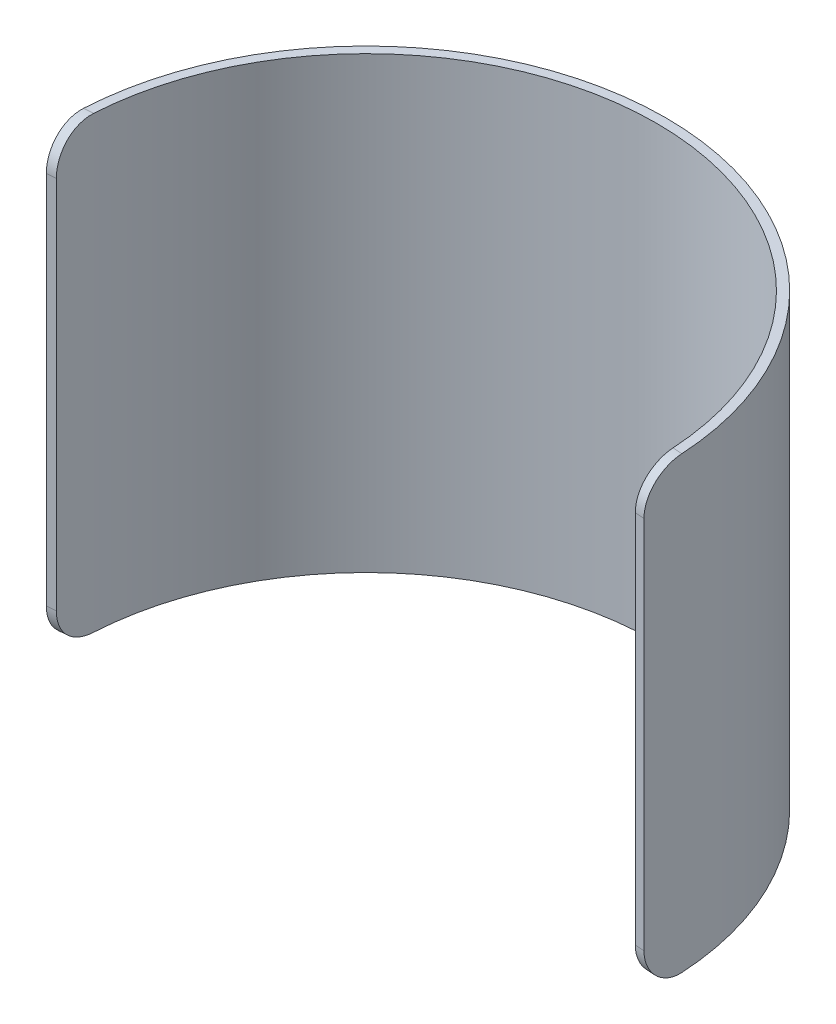
from build123d import *

# Parameters (mm, degrees)
SKETCH1_R           = 101.6
SKETCH1_R_2         = 98.425
BOSS_EXTRUDE1_DEPTH = 152.4
CUT_EXTRUDE1_DEPTH  = 152.4
FILLET1_R           = 12.7


with BuildPart() as part:
    # Sketch1 → Boss-Extrude1 (new body)
    with BuildSketch(Plane(origin=(0, 0, 0), x_dir=(1, 0, 0), z_dir=(0, 1, 0))):
        Circle(SKETCH1_R)
        Circle(SKETCH1_R_2, mode=Mode.SUBTRACT)
    extrude(amount=BOSS_EXTRUDE1_DEPTH)

    # Sketch2 → Cut-Extrude1 (cut)
    with BuildSketch(Plane(origin=(0, 0, 0), x_dir=(1, 0, 0), z_dir=(0, 1, 0))):
        Polygon((570.652570484, -39.903914981), (101.352507506, -7.087257732), (0, 0), (-101.352507506, -7.087257732), (-570.652570484, -39.903914981), (-570.652570484, -980.796006784), (570.652570484, -980.796006784), align=None)
    extrude(amount=CUT_EXTRUDE1_DEPTH, mode=Mode.SUBTRACT)

    # Fillet1
    fillet1_edges = [part.edges().sort_by_distance(p)[0] for p in [
        (-99.768874577, 0, 6.97651933),
        (99.768874577, 152.4, 6.97651933),
        (-99.768874577, 152.4, 6.97651933),
        (99.768874577, 0, 6.97651933),
    ]]
    fillet(fillet1_edges, radius=FILLET1_R)


solid = part.part
